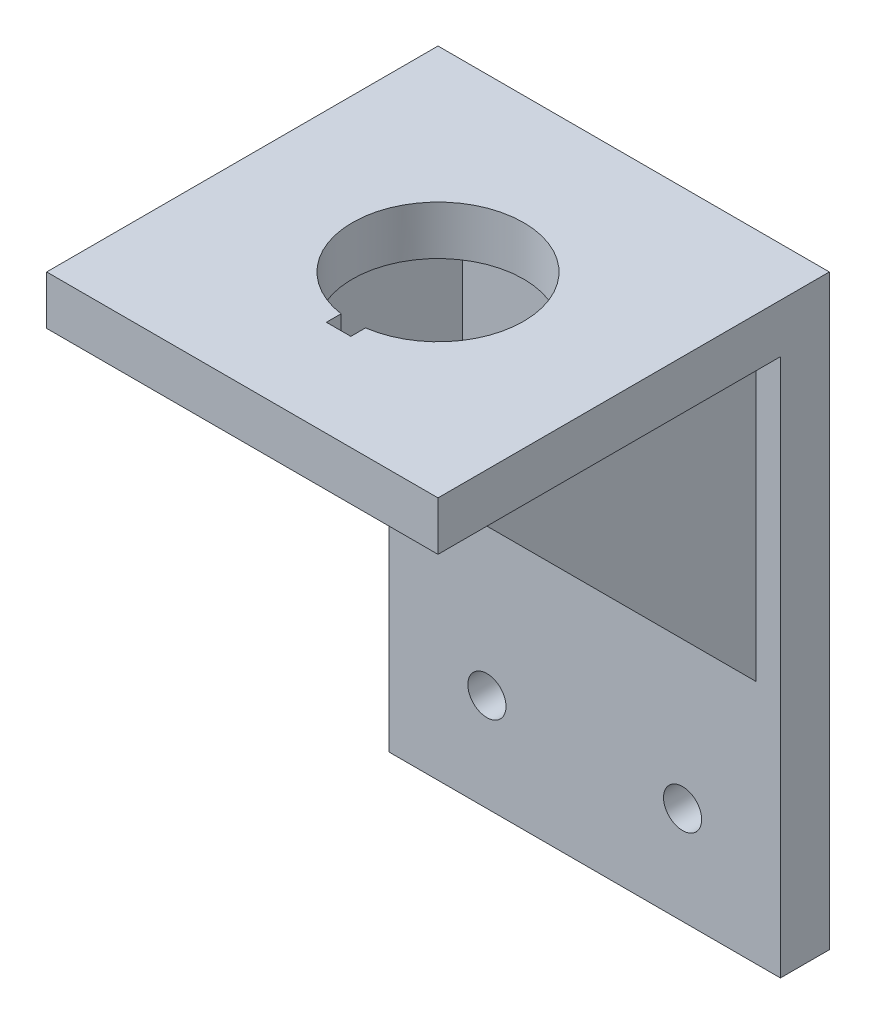
from build123d import *

# Parameters (mm, degrees)
SKETCH1_W           = 50.8
SKETCH1_H           = 76.2
SKETCH1_R           = 2.4765
BOSS_EXTRUDE1_DEPTH = 6.35
SKETCH2_R           = 2.2225
BOSS_EXTRUDE2_DEPTH = 3.175
SKETCH3_W           = 6.35
SKETCH3_H           = 3.175
CUT_EXTRUDE1_DEPTH  = 10.525
SKETCH4_W           = 50.8
SKETCH4_H           = 44.45
BOSS_EXTRUDE3_DEPTH = 6.35
BOSS_EXTRUDE4_DEPTH = 22.225
SKETCH6_W           = 31.75
SKETCH6_H           = 38.1
CUT_EXTRUDE2_DEPTH  = 45.45
SKETCH7_R           = 11.1125
CUT_EXTRUDE3_DEPTH  = 7.35
SKETCH8_W           = 3.175
SKETCH8_H           = 1.905
CUT_EXTRUDE4_DEPTH  = 2.2225


with BuildPart() as part:
    # Sketch1 → Boss-Extrude1 (new body)
    with BuildSketch(Plane.XY):
        Rectangle(SKETCH1_W, SKETCH1_H)
        with Locations((-12.7, -25.4)):
            Circle(SKETCH1_R, mode=Mode.SUBTRACT)
        with Locations((12.7, -25.4)):
            Circle(SKETCH1_R, mode=Mode.SUBTRACT)
        with Locations((0, 25.4)):
            Circle(SKETCH1_R, mode=Mode.SUBTRACT)
    extrude(amount=BOSS_EXTRUDE1_DEPTH)

    # Sketch2 → Boss-Extrude2 (add)
    with BuildSketch(Plane(origin=(0, 0, 0), x_dir=(-1, 0, 0), z_dir=(0, 0, -1))):
        with Locations((-12.7, 25.4)):
            Circle(SKETCH2_R)
        with Locations((12.7, 25.4)):
            Circle(SKETCH2_R)
        with BuildLine():
            ThreePointArc((-5.08, 13.340296662), (-7.1374, 12.362339434), (-9.013035804, 11.069557382))
            ThreePointArc((-9.013035804, 11.069557382), (-10.265964814, 10.566776235), (-11.582919047, 10.863847829))
            ThreePointArc((-11.582919047, 10.863847829), (-12.926326796, 11.078530787), (-14.070368319, 10.342322835))
            ThreePointArc((-14.070368319, 10.342322835), (-15.122968614, 8.73125), (-15.991898469, 7.014134987))
            ThreePointArc((-15.991898469, 7.014134987), (-16.057452496, 5.65526199), (-15.199827727, 4.59917823))
            ThreePointArc((-15.199827727, 4.59917823), (-14.284079063, 3.607198205), (-14.093035804, 2.27073928))
            ThreePointArc((-14.093035804, 2.27073928), (-14.2748, 0), (-14.093035804, -2.27073928))
            ThreePointArc((-14.093035804, -2.27073928), (-14.284079063, -3.607198205), (-15.199827727, -4.59917823))
            ThreePointArc((-15.199827727, -4.59917823), (-16.057452496, -5.65526199), (-15.991898469, -7.014134987))
            ThreePointArc((-15.991898469, -7.014134987), (-15.122968614, -8.73125), (-14.070368319, -10.342322835))
            ThreePointArc((-14.070368319, -10.342322835), (-12.926326796, -11.078530787), (-11.582919047, -10.863847829))
            ThreePointArc((-11.582919047, -10.863847829), (-10.265964814, -10.566776235), (-9.013035804, -11.069557382))
            ThreePointArc((-9.013035804, -11.069557382), (-7.1374, -12.362339434), (-5.08, -13.340296662))
            ThreePointArc((-5.08, -13.340296662), (-4.018114249, -14.173974441), (-3.616908679, -15.46302606))
            ThreePointArc((-3.616908679, -15.46302606), (-3.1311257, -16.733792777), (-1.92153015, -17.356457822))
            ThreePointArc((-1.92153015, -17.356457822), (0, -17.4625), (1.92153015, -17.356457822))
            ThreePointArc((1.92153015, -17.356457822), (3.1311257, -16.733792777), (3.616908679, -15.46302606))
            ThreePointArc((3.616908679, -15.46302606), (4.018114249, -14.173974441), (5.08, -13.340296662))
            ThreePointArc((5.08, -13.340296662), (7.1374, -12.362339434), (9.013035804, -11.069557382))
            ThreePointArc((9.013035804, -11.069557382), (10.265964814, -10.566776235), (11.582919047, -10.863847829))
            ThreePointArc((11.582919047, -10.863847829), (12.926326796, -11.078530787), (14.070368319, -10.342322835))
            ThreePointArc((14.070368319, -10.342322835), (15.122968614, -8.73125), (15.991898469, -7.014134987))
            ThreePointArc((15.991898469, -7.014134987), (16.057452496, -5.65526199), (15.199827727, -4.59917823))
            ThreePointArc((15.199827727, -4.59917823), (14.284079063, -3.607198205), (14.093035804, -2.27073928))
            ThreePointArc((14.093035804, -2.27073928), (14.2748, 0), (14.093035804, 2.27073928))
            ThreePointArc((14.093035804, 2.27073928), (14.284079063, 3.607198205), (15.199827727, 4.59917823))
            ThreePointArc((15.199827727, 4.59917823), (16.057452496, 5.65526199), (15.991898469, 7.014134987))
            ThreePointArc((15.991898469, 7.014134987), (15.122968614, 8.73125), (14.070368319, 10.342322835))
            ThreePointArc((14.070368319, 10.342322835), (12.926326796, 11.078530787), (11.582919047, 10.863847829))
            ThreePointArc((11.582919047, 10.863847829), (10.265964814, 10.566776235), (9.013035804, 11.069557382))
            ThreePointArc((9.013035804, 11.069557382), (7.1374, 12.362339434), (5.08, 13.340296662))
            ThreePointArc((5.08, 13.340296662), (4.018114249, 14.173974441), (3.616908679, 15.46302606))
            ThreePointArc((3.616908679, 15.46302606), (3.1311257, 16.733792777), (1.92153015, 17.356457822))
            ThreePointArc((1.92153015, 17.356457822), (0, 17.4625), (-1.92153015, 17.356457822))
            ThreePointArc((-1.92153015, 17.356457822), (-3.1311257, 16.733792777), (-3.616908679, 15.46302606))
            ThreePointArc((-3.616908679, 15.46302606), (-4.018114249, 14.173974441), (-5.08, 13.340296662))
        make_face()
    extrude(amount=BOSS_EXTRUDE2_DEPTH)

    # Sketch3 → Cut-Extrude1 (cut, through all)
    with BuildSketch(Plane(origin=(0, 0, -3.175), x_dir=(-1, 0, 0), z_dir=(0, 0, -1))):
        Rectangle(SKETCH3_W, SKETCH3_H)
    extrude(amount=-CUT_EXTRUDE1_DEPTH, mode=Mode.SUBTRACT)

    # Sketch4 → Boss-Extrude3 (add)
    with BuildSketch(Plane(origin=(0, 38.1, 0), x_dir=(1, 0, 0), z_dir=(0, 1, 0))):
        with Locations((0, -28.575)):
            Rectangle(SKETCH4_W, SKETCH4_H)
    extrude(amount=-BOSS_EXTRUDE3_DEPTH)

    # Sketch5 → Boss-Extrude4 (add, symmetric)
    with BuildSketch(Plane(origin=(0, 0, 0), x_dir=(0, 0, -1), z_dir=(1, 0, 0))):
        Polygon((-44.45, 31.75), (-6.35, -6.35), (-6.35, 31.75), align=None)
    extrude(amount=BOSS_EXTRUDE4_DEPTH, both=True)

    # Sketch6 → Cut-Extrude2 (cut, through all)
    with BuildSketch(Plane.XY.offset(6.35)):
        with Locations((0, 12.7)):
            Rectangle(SKETCH6_W, SKETCH6_H)
    extrude(amount=CUT_EXTRUDE2_DEPTH, mode=Mode.SUBTRACT)

    # Sketch7 → Cut-Extrude3 (cut, through all)
    with BuildSketch(Plane.XZ.offset(-31.75)):
        with Locations((0, 25.4)):
            Circle(SKETCH7_R)
    extrude(amount=-CUT_EXTRUDE3_DEPTH, mode=Mode.SUBTRACT)

    # Sketch8 → Cut-Extrude4 (cut)
    with BuildSketch(Plane(origin=(0, 38.1, 0), x_dir=(1, 0, 0), z_dir=(0, 1, 0))):
        with Locations((0, -37.351022628)):
            Rectangle(SKETCH8_W, SKETCH8_H)
    extrude(amount=-CUT_EXTRUDE4_DEPTH, mode=Mode.SUBTRACT)


solid = part.part
